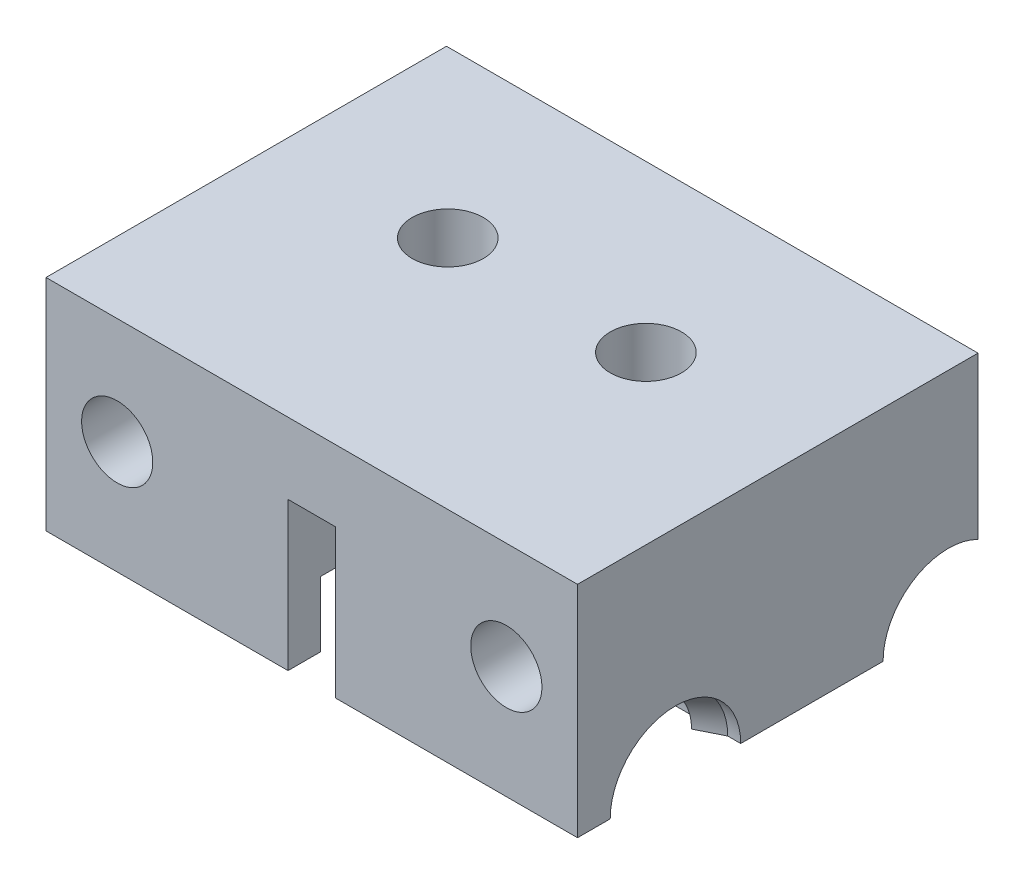
from build123d import *

# Parameters (mm, degrees)
REVOLVE1_ANGLE           = 180
BOSS_EXTRUDE1_DEPTH      = 9.25
BOSS_EXTRUDE1_DEPTH_BACK = 9.25
BOSS_EXTRUDE2_START      = 3.5
BOSS_EXTRUDE2_DEPTH      = 5.75
BOSS_EXTRUDE3_START      = -3.5
BOSS_EXTRUDE3_DEPTH      = 5.75
SKETCH14_W               = 2.5
SKETCH14_H               = 5
CUT_EXTRUDE10_DEPTH      = 17.487950145
SKETCH13_W               = 5.5
SKETCH13_H               = 2.75
CUT_EXTRUDE9_DEPTH       = 1.75
SKETCH15_W               = 12.7
SKETCH15_H               = 8
CUT_EXTRUDE11_DEPTH      = 25.836515456
SKETCH16_W               = 5.122625222
SKETCH16_H               = 5
CUT_EXTRUDE12_DEPTH      = 19.677593528
SKETCH22_W               = 2.5
SKETCH22_H               = 5
CUT_EXTRUDE17_DEPTH      = 22.705662381
SKETCH17_W               = 10.2
SKETCH17_H               = 16.877374778
BOSS_EXTRUDE4_DEPTH      = 4.25
SKETCH18_R               = 1.5
CUT_EXTRUDE13_DEPTH      = 28.275588567
SKETCH19_R               = 1.5
CUT_EXTRUDE14_DEPTH      = 27.141829157
SKETCH20_R               = 1.5
CUT_EXTRUDE16_DEPTH      = 24.804137104
SKETCH23_W               = 16.877374778
SKETCH23_H               = 3
BOSS_EXTRUDE5_DEPTH      = 1


with BuildPart() as part:
    # Sketch6 → Revolve1 (revolve)
    with BuildSketch(Plane(origin=(0, 0, 0), x_dir=(1, 0, 0), z_dir=(0, 1, 0))):
        Polygon((0, 5), (0, 2.75), (3.81, 2.75), (3.81, 2.242), (4.826, 2.75), (8.636, 2.75), (8.636, 2.242), (9.652, 2.75), (12.7, 2.75), (12.7, 5), align=None)
    revolve(axis=Axis((0, 0, 0), (1, 0, 0)), revolution_arc=REVOLVE1_ANGLE)

    # Sketch9 → Boss-Extrude1 (add, two sides: drawn at the far end of the back side and taken through both)
    with BuildSketch(Plane.XY.offset(-BOSS_EXTRUDE1_DEPTH_BACK)):
        Polygon((0, 5), (0, 3.25), (12.7, 2.75), (12.7, 5), align=None)
    extrude(amount=BOSS_EXTRUDE1_DEPTH + BOSS_EXTRUDE1_DEPTH_BACK)

    # Sketch9_3 → Boss-Extrude2 (add)
    with BuildSketch(Plane.XY.offset(BOSS_EXTRUDE2_START)):
        Polygon((0, 3.25), (0, 0), (12.7, 0), (12.7, 2.75), align=None)
    extrude(amount=BOSS_EXTRUDE2_DEPTH)

    # Sketch9_4 → Boss-Extrude3 (add)
    with BuildSketch(Plane.XY.offset(BOSS_EXTRUDE3_START)):
        Polygon((0, 3.25), (0, 0), (12.7, 0), (12.7, 2.75), align=None)
    extrude(amount=-BOSS_EXTRUDE3_DEPTH)

    # Sketch14 → Cut-Extrude10 (cut, through all)
    with BuildSketch(Plane.ZY):
        with Locations((-8, 2.5)):
            Rectangle(SKETCH14_W, SKETCH14_H)
    extrude(amount=-CUT_EXTRUDE10_DEPTH, mode=Mode.SUBTRACT)

    # Mirror4: part across plane


with BuildPart() as part_1:
    add(part.part)
    add(part.part.mirror(Plane.XY.offset(-5.75)))

    # Sketch13 → Cut-Extrude9 (cut)
    with BuildSketch(Plane.ZY):
        with Locations((0, 1.375)):
            Rectangle(SKETCH13_W, SKETCH13_H)
    extrude(amount=-CUT_EXTRUDE9_DEPTH, mode=Mode.SUBTRACT)

    # Sketch15 → Cut-Extrude11 (cut, through all)
    with BuildSketch(Plane(origin=(0, 5, 0), x_dir=(1, 0, 0), z_dir=(0, 1, 0))):
        with Locations((6.35, 16.75)):
            Rectangle(SKETCH15_W, SKETCH15_H)
    extrude(amount=-CUT_EXTRUDE11_DEPTH, mode=Mode.SUBTRACT)

    # Sketch16 → Cut-Extrude12 (cut, through all)
    with BuildSketch(Plane.ZY):
        with Locations((6.688687389, 2.5)):
            Rectangle(SKETCH16_W, SKETCH16_H)
    extrude(amount=-CUT_EXTRUDE12_DEPTH, mode=Mode.SUBTRACT)

    # Sketch22 → Cut-Extrude17 (cut, through all)
    with BuildSketch(Plane.XY.offset(4.127374778)):
        with Locations((11.45, 2.5)):
            Rectangle(SKETCH22_W, SKETCH22_H)
    extrude(amount=-CUT_EXTRUDE17_DEPTH, mode=Mode.SUBTRACT)


with BuildPart() as body_2:
    # Mirror8: mirrored copy
    add(part_1.part.mirror(Plane.XY.offset(5.397374778)))

    # Sketch19 → Cut-Extrude14 (cut, through all)
    with BuildSketch(Plane(origin=(0, 5, 0), x_dir=(1, 0, 0), z_dir=(0, 1, 0))):
        with Locations((3.175, -16.573374778)):
            Circle(SKETCH19_R)
    extrude(amount=-CUT_EXTRUDE14_DEPTH, mode=Mode.SUBTRACT)


with BuildPart() as part_2:
    add(part_1.part)

    # Sketch17 → Boss-Extrude4 (add)
    with BuildSketch(Plane(origin=(0, 5, 0), x_dir=(1, 0, 0), z_dir=(0, 1, 0))):
        with Locations((5.1, 4.311312611)):
            Rectangle(SKETCH17_W, SKETCH17_H)
    extrude(amount=BOSS_EXTRUDE4_DEPTH)

    # Sketch18 → Cut-Extrude13 (cut, through all)
    with BuildSketch(Plane(origin=(0, 9.25, 0), x_dir=(1, 0, 0), z_dir=(0, 1, 0))):
        with Locations((3.175, 5.778625222)):
            Circle(SKETCH18_R)
    extrude(amount=-CUT_EXTRUDE13_DEPTH, mode=Mode.SUBTRACT)

    # Sketch20 → Cut-Extrude16 (cut, through all)
    with BuildSketch(Plane.XY.offset(4.127374778)):
        with Locations((7.2, 4.75)):
            Circle(SKETCH20_R)
    extrude(amount=-CUT_EXTRUDE16_DEPTH, mode=Mode.SUBTRACT)

    # Sketch23 → Boss-Extrude5 (add)
    with BuildSketch(Plane.ZY):
        with Locations((-4.311312611, 7.75)):
            Rectangle(SKETCH23_W, SKETCH23_H)
    extrude(amount=BOSS_EXTRUDE5_DEPTH)


with BuildPart() as body_3:
    # Mirror9: mirrored copy
    add(part_2.part.mirror(Plane.ZY.offset(1)))

    # Combine1: union part
    add(part_2.part)


solid = body_3.part
